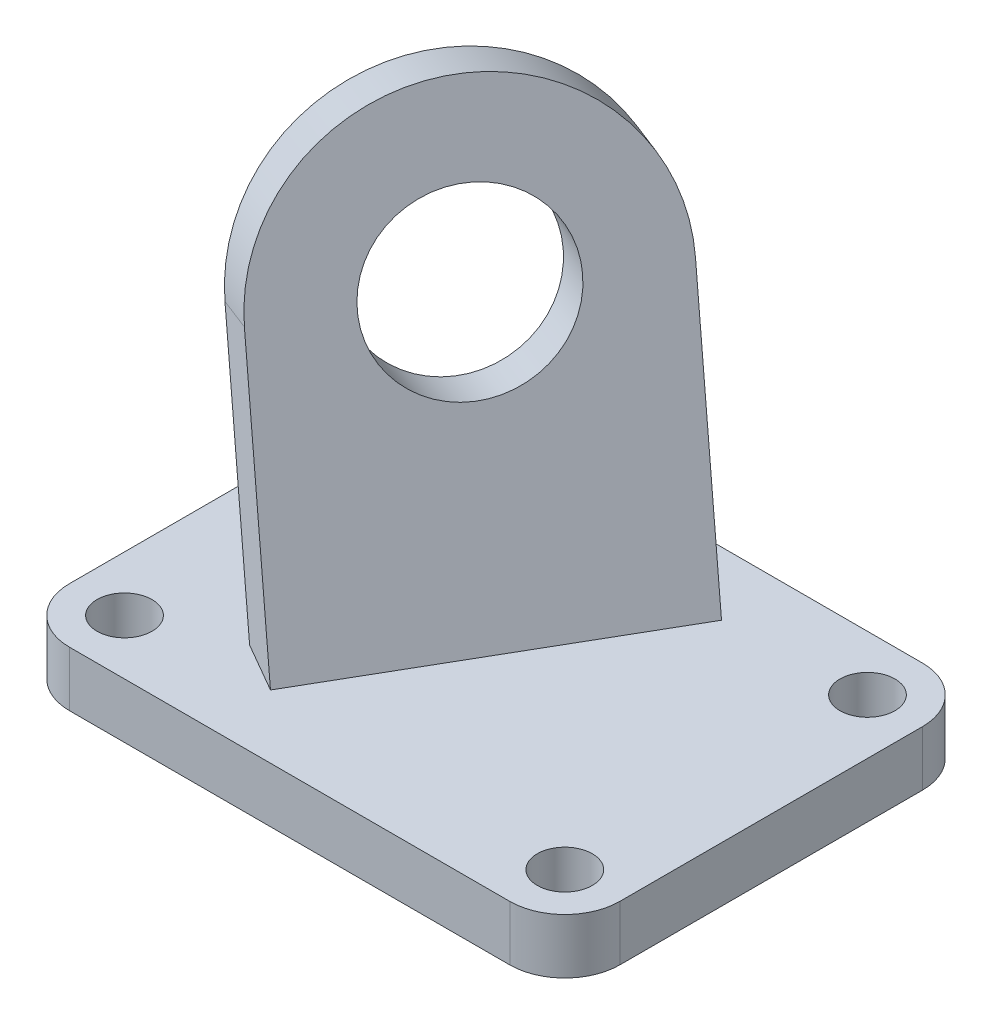
from build123d import *

# Parameters (mm, degrees)
SKETCH_1_R      = 5
EXTRUDE_1_DEPTH = 10
SKETCH_3_R      = 15
EXTRUDE_2_DEPTH = 10


with BuildPart() as part:
    # 草圖1 → 填料-伸長1 (new body)
    with BuildSketch(Plane(origin=(0, 0, 0), x_dir=(1, 0, 0), z_dir=(0, 1, 0))):
        with BuildLine():
            Line((-40, -37.5), (40, -37.5))
            ThreePointArc((40, -37.5), (47.071067812, -34.571067812), (50, -27.5))
            Line((50, -27.5), (50, 27.5))
            ThreePointArc((50, 27.5), (47.071067812, 34.571067812), (40, 37.5))
            Line((40, 37.5), (-40, 37.5))
            ThreePointArc((-40, 37.5), (-47.071067812, 34.571067812), (-50, 27.5))
            Line((-50, 27.5), (-50, -27.5))
            ThreePointArc((-50, -27.5), (-47.071067812, -34.571067812), (-40, -37.5))
        make_face()
        with Locations((-40, 27.5)):
            Circle(SKETCH_1_R, mode=Mode.SUBTRACT)
        with Locations((40, 27.5)):
            Circle(SKETCH_1_R, mode=Mode.SUBTRACT)
        with Locations((-40, -27.5)):
            Circle(SKETCH_1_R, mode=Mode.SUBTRACT)
        with Locations((40, -27.5)):
            Circle(SKETCH_1_R, mode=Mode.SUBTRACT)
    extrude(amount=-EXTRUDE_1_DEPTH)

    # 草圖3 → 填料-伸長2 (add)
    with BuildSketch(Plane(origin=(0, 0, 0), x_dir=(0.500000000000001, 0, -0.866025403784438), z_dir=(0.8365163037378073, 0.25881904510252135, 0.48296291314453504))):
        with BuildLine():
            Line((-30, 50), (-30, 0))
            Line((-30, 0), (30, 0))
            Line((30, 0), (30, 50))
            ThreePointArc((30, 50), (0, 80), (-30, 50))
        make_face()
        with Locations((0, 50)):
            Circle(SKETCH_3_R, mode=Mode.SUBTRACT)
    extrude(amount=-EXTRUDE_2_DEPTH)


solid = part.part
